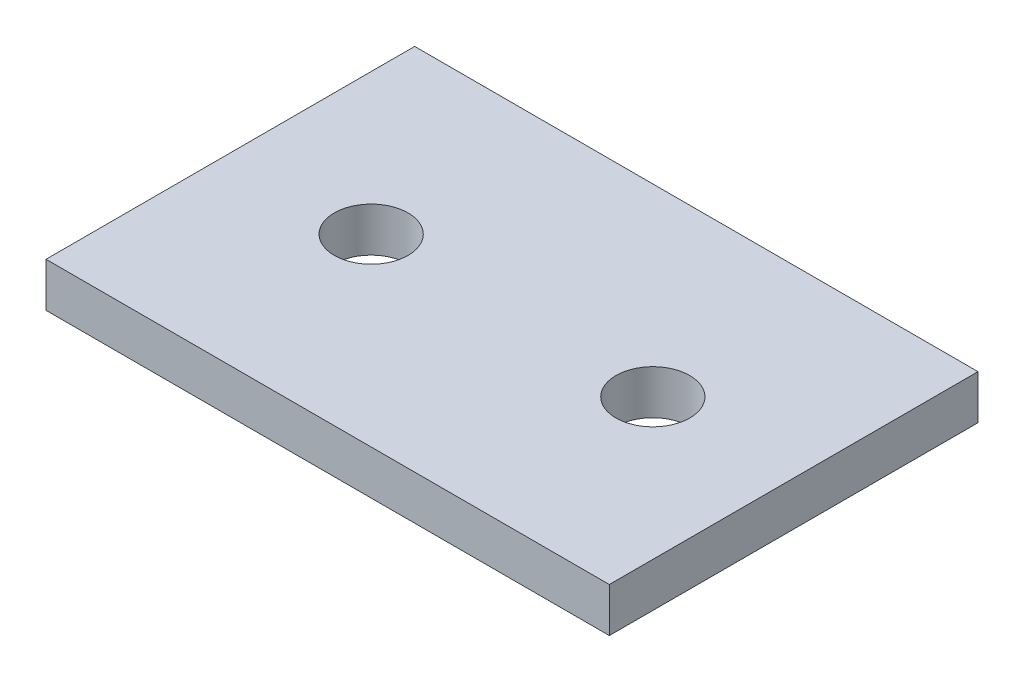
from build123d import *

# Parameters (mm, degrees)
CROQUIS1_W              = 38.2
CROQUIS1_H              = 25
SALIENTE_EXTRUIR1_DEPTH = 3
CROQUIS2_R              = 2.5
CORTAR_EXTRUIR1_DEPTH   = 3


with BuildPart() as part:
    # Croquis1 → Saliente-Extruir1 (new body)
    with BuildSketch(Plane(origin=(0, 0, 0), x_dir=(1, 0, 0), z_dir=(0, 1, 0))):
        with Locations((-19.1, 12.5)):
            Rectangle(CROQUIS1_W, CROQUIS1_H)
    extrude(amount=SALIENTE_EXTRUIR1_DEPTH)

    # Croquis2 → Cortar-Extruir1 (cut)
    with BuildSketch(Plane(origin=(0, 3, 0), x_dir=(1, 0, 0), z_dir=(0, 1, 0))):
        with Locations((-28.65, 12.5)):
            Circle(CROQUIS2_R)
        with Locations((-9.55, 12.5)):
            Circle(CROQUIS2_R)
    extrude(amount=-CORTAR_EXTRUIR1_DEPTH, mode=Mode.SUBTRACT)


solid = part.part
